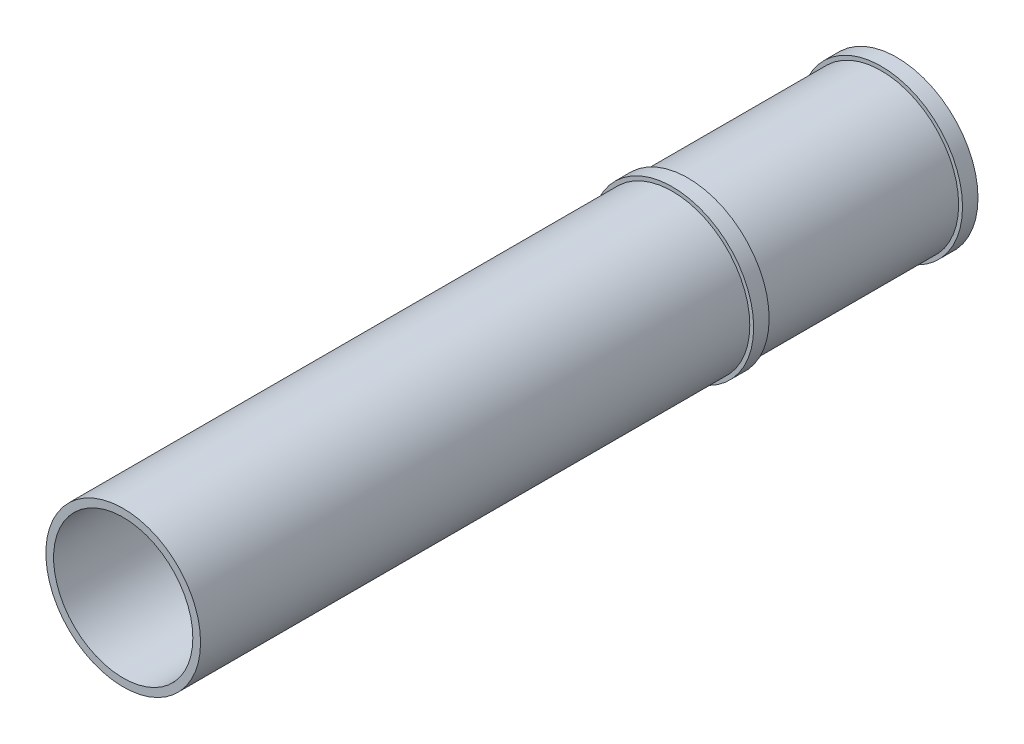
from build123d import *

# Parameters (mm, degrees)
SKETCH2_R           = 20
SKETCH2_R_2         = 18
BOSS_EXTRUDE1_DEPTH = 200
SKETCH2_3_R         = 21
SKETCH2_3_R_2       = 20
BOSS_EXTRUDE2_DEPTH = 4
BOSS_EXTRUDE3_START = 54
SKETCH2_4_R         = 21
SKETCH2_4_R_2       = 20
BOSS_EXTRUDE3_DEPTH = 4


with BuildPart() as part:
    # Sketch2 → Boss-Extrude1 (new body)
    with BuildSketch(Plane.XY):
        Circle(SKETCH2_R)
        Circle(SKETCH2_R_2, mode=Mode.SUBTRACT)
    extrude(amount=BOSS_EXTRUDE1_DEPTH)

    # Sketch2_3 → Boss-Extrude2 (add)
    with BuildSketch(Plane.XY):
        Circle(SKETCH2_3_R)
        Circle(SKETCH2_3_R_2, mode=Mode.SUBTRACT)
    extrude(amount=BOSS_EXTRUDE2_DEPTH)

    # Sketch2_4 → Boss-Extrude3 (add)
    with BuildSketch(Plane.XY.offset(BOSS_EXTRUDE3_START)):
        Circle(SKETCH2_4_R)
        Circle(SKETCH2_4_R_2, mode=Mode.SUBTRACT)
    extrude(amount=BOSS_EXTRUDE3_DEPTH)


solid = part.part
